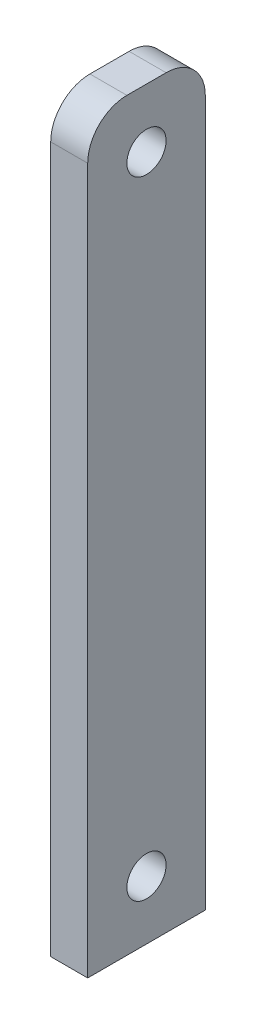
from build123d import *

# Parameters (mm, degrees)
SKETCH1_W      = 9.525
SKETCH1_H      = 60.325
SKETCH1_R      = 1.5875
EXTRUDE1_DEPTH = 1.4986
FILLET1_R      = 3.175


with BuildPart() as part:
    # Sketch1 → Extrude1 (new body, symmetric)
    with BuildSketch(Plane(origin=(0, 0, 0), x_dir=(0, 0, -1), z_dir=(1, 0, 0))):
        with Locations((0, 25.4)):
            Rectangle(SKETCH1_W, SKETCH1_H)
        Circle(SKETCH1_R, mode=Mode.SUBTRACT)
        with Locations((0, 50.8)):
            Circle(SKETCH1_R, mode=Mode.SUBTRACT)
    extrude(amount=EXTRUDE1_DEPTH, both=True)

    # Fillet1
    fillet1_edges = [part.edges().sort_by_distance(p)[0] for p in [
        (0, 55.5625, 4.7625),
        (0, 55.5625, -4.7625),
    ]]
    fillet(fillet1_edges, radius=FILLET1_R)


solid = part.part
